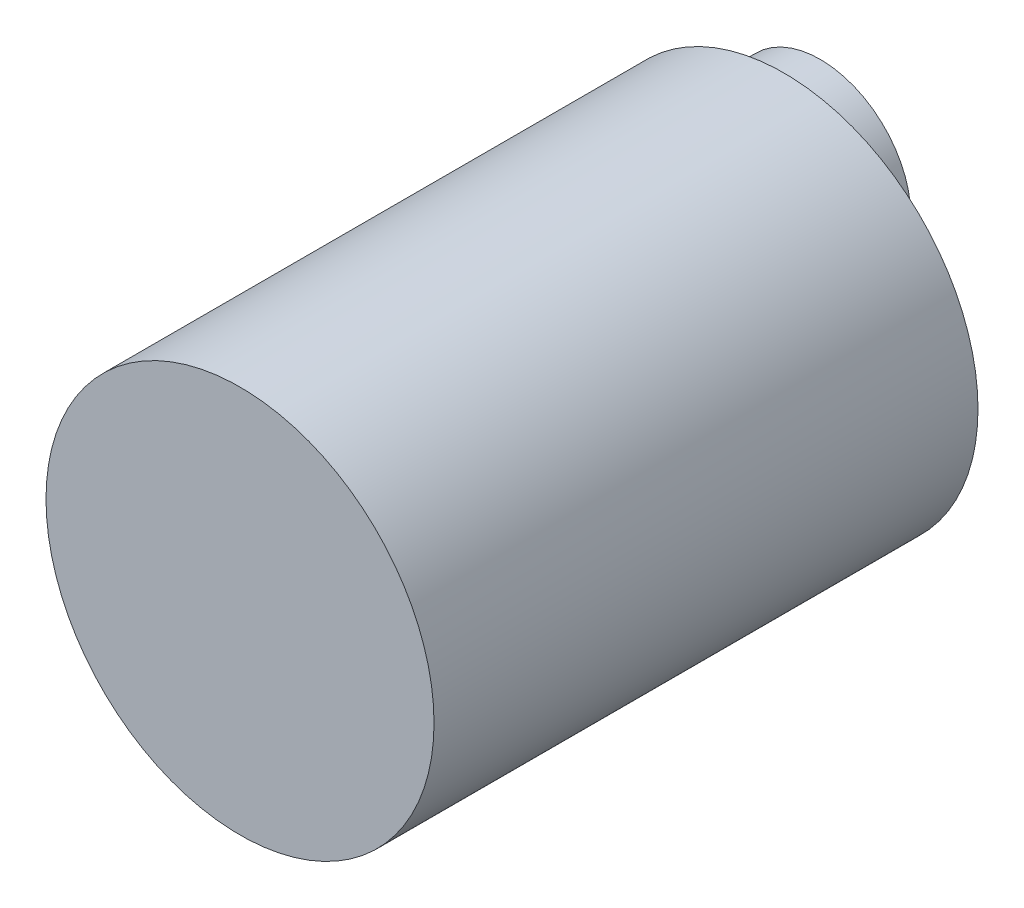
from build123d import *

# Parameters (mm, degrees)
SKETCH1_R           = 13.589
BOSS_EXTRUDE2_DEPTH = 38.1
SKETCH1_5_R         = 6.35
BOSS_EXTRUDE3_DEPTH = 2.54


with BuildPart() as part:
    # Sketch1 → Boss-Extrude2 (new body)
    with BuildSketch(Plane.XY):
        Circle(SKETCH1_R)
    extrude(amount=BOSS_EXTRUDE2_DEPTH)

    # Sketch1_5 → Boss-Extrude3 (add)
    with BuildSketch(Plane.XY):
        with Locations((0, 6.7945)):
            Circle(SKETCH1_5_R)
    extrude(amount=-BOSS_EXTRUDE3_DEPTH)


solid = part.part
